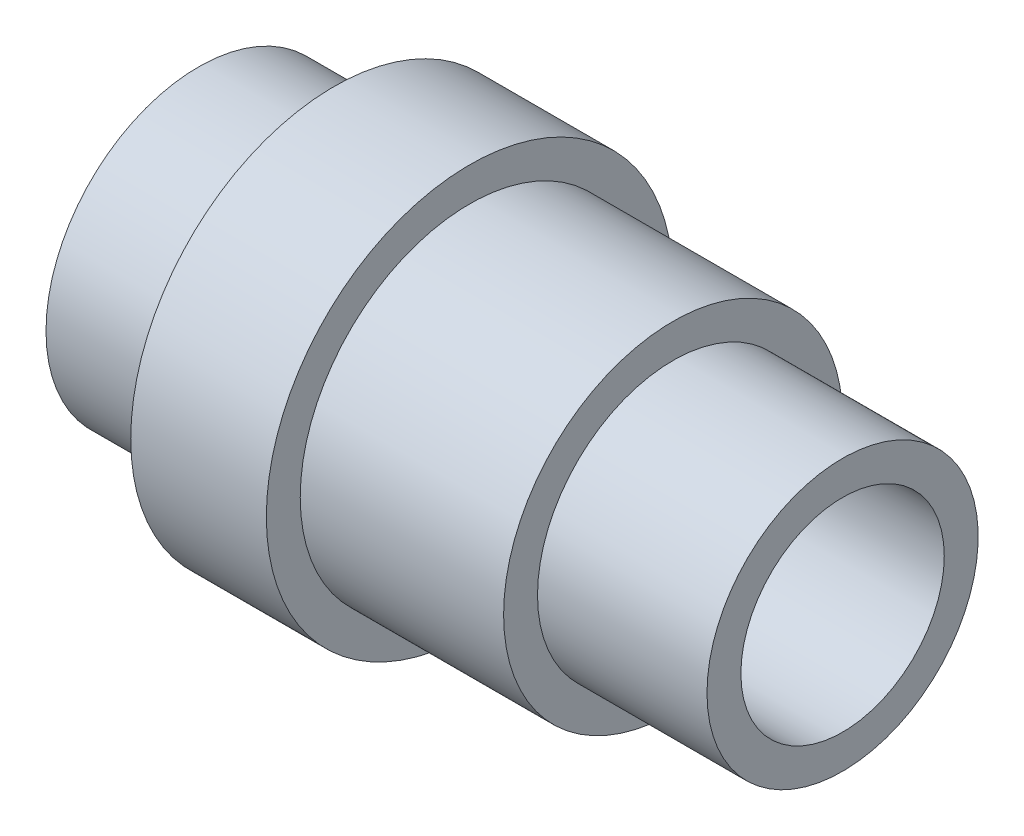
from build123d import *


with BuildPart() as part:
    # Sketch1 → Revolve1 (revolve)
    with BuildSketch(Plane.XY):
        Polygon((-47.5, 22.5), (-47.5, 15), (47.5, 15), (47.5, 20), (22.5, 20), (22.5, 25), (-7.5, 25), (-7.5, 30), (-27.5, 30), (-27.5, 22.5), align=None)
    revolve(axis=Axis((-25.953878407, 0, 0), (1, 0, 0)))


solid = part.part
